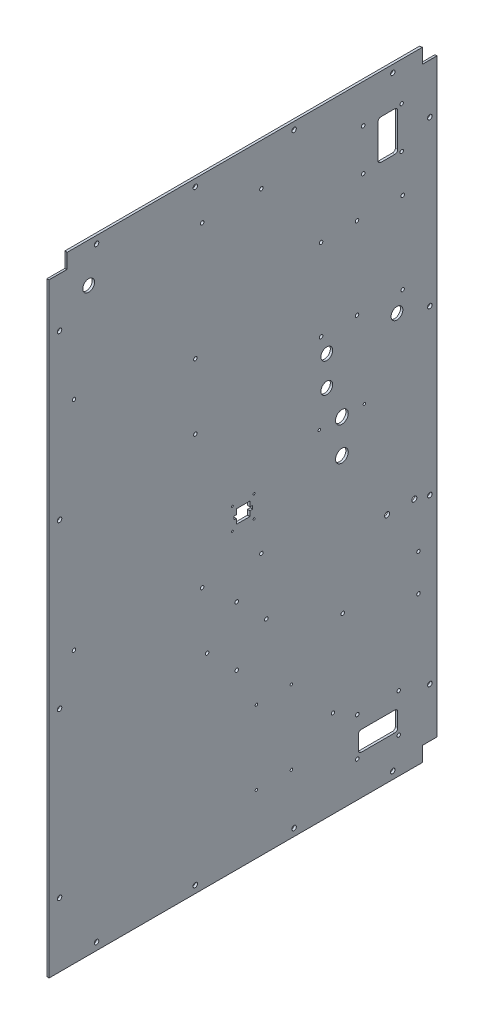
from build123d import *

# Parameters (mm, degrees)
SKETCH1_W                                   = 499.3132
SKETCH1_H                                   = 797.0266
SIDEPANEL_DEPTH                             = 3.0734
SKETCH2_R                                   = 2.8956
TOPBOTTOMHOLEMASTER_DEPTH                   = 4.0734
LPATTERN1_COUNT                             = 4
LPATTERN1_PITCH                             = 127.067733333
SKETCH3_R                                   = 2.8956
REARHOLESMASTER_DEPTH                       = 4.0734
LPATTERN2_COUNT                             = 4
LPATTERN2_PITCH                             = 210.574466667
SKETCH4_W                                   = 19.05
SKETCH4_H                                   = 19.05
SKETCH4_W_2                                 = 22.86
CORNERCUTS_DEPTH                            = 4.0734
F_8_CLEARANCE_HOLE4_BRAIN_MOUNT_D           = 4.4958
F_8_CLEARANCE_HOLE3_PUMP_MOUNTS_D           = 4.4958
SKETCH17_W                                  = 25.4
SKETCH17_H                                  = 50.8
SKETCH17_W_2                                = 50.8
SKETCH17_H_2                                = 25.4
CABLE_PASS_THROUGH_DEPTH                    = 4.0734
F_8_CLEARANCE_HOLE1_PASS_THROUGH_MOUNTING_D = 4.4958
CUT_EXTRUDE1_DEPTH                          = 2.54
F_8_CLEARANCE_HOLE_HX_MOUNT_D               = 4.4958
SKETCH42_R                                  = 7.578725
SKETCH42_R_2                                = 7.5819
COOLANT_HOSE_PASS_THROUGH_DEPTH             = 4.0734
SKETCH43_R                                  = 7.5819
AIR_FLUSH_IN_OUT_DEPTH                      = 4.0734
F_8_CLEARANCE_HOLE2_AIR_FLUSH_OUT_MOUNT_D   = 4.4958
F_8_CLEARANCE_HOLE4_PANEL_MOUNTS_D          = 4.4958
FILLET1_R                                   = 3.81
SKETCH50_OUTSIDE_W                          = 689.418
SKETCH50_OUTSIDE_H                          = 987.13
SKETCH50_OUTSIDE_R                          = 8.1915
SENSOR_MOUNTING_DEPTH                       = 4.0734
F_2_CLEARANCE_HOLE1_D                       = 2.4384
F_4_CLEARANCE_HOLE2_D                       = 3.2639
FILLET2_R                                   = 0.127
F_4_CLEARANCE_HOLE_COMPRESSOR_DRIVER_D      = 3.2639
F_1_4_CLEARANCE_HOLE_BALL_VALVE_U_BOLT_D    = 6.5278
AERATION_PUMP_8_CLEARANCE_HOLE1_D           = 4.3053


with BuildPart() as part:
    # Sketch1 → SidePanel (new body)
    with BuildSketch(Plane(origin=(0, 0, 0), x_dir=(0, 0, -1), z_dir=(1, 0, 0))):
        Rectangle(SKETCH1_W, SKETCH1_H)
    extrude(amount=SIDEPANEL_DEPTH)

    # Sketch2 → TopBottomHoleMaster (cut, through all)
    with BuildSketch(Plane(origin=(3.0734, 0, 0), x_dir=(0, 0, -1), z_dir=(1, 0, 0))):
        with Locations((192.5066, 388.9883)):
            Circle(SKETCH2_R)
        with Locations((192.5066, -388.9883)):
            Circle(SKETCH2_R)
    topbottomholemaster = extrude(amount=-TOPBOTTOMHOLEMASTER_DEPTH, mode=Mode.SUBTRACT)

    # LPattern1: TopBottomHoleMaster ×4
    with Locations(*[(0, 0, i * LPATTERN1_PITCH) for i in range(1, LPATTERN1_COUNT)]):
        add(topbottomholemaster, mode=Mode.SUBTRACT)

    # Sketch3 → RearHolesMaster (cut, through all)
    with BuildSketch(Plane(origin=(3.0734, 0, 0), x_dir=(0, 0, -1), z_dir=(1, 0, 0))):
        with Locations((-236.3216, 315.8617)):
            Circle(SKETCH3_R)
        with Locations((240.1316, 315.8617)):
            Circle(SKETCH3_R)
    rearholesmaster = extrude(amount=-REARHOLESMASTER_DEPTH, mode=Mode.SUBTRACT)

    # LPattern2: RearHolesMaster ×4
    with Locations(*[(0, -i * LPATTERN2_PITCH, 0) for i in range(1, LPATTERN2_COUNT)]):
        add(rearholesmaster, mode=Mode.SUBTRACT)

    # Sketch4 → CornerCuts (cut, through all)
    with BuildSketch(Plane.ZY):
        with Locations((-240.1316, 388.9883)):
            Rectangle(SKETCH4_W, SKETCH4_H)
        with Locations((238.2266, 388.9883)):
            Rectangle(SKETCH4_W_2, SKETCH4_H)
        with Locations((-240.1316, -388.9883)):
            Rectangle(SKETCH4_W, SKETCH4_H)
    extrude(amount=-CORNERCUTS_DEPTH, mode=Mode.SUBTRACT)

    # #8 Clearance Hole4 Brain Mount (through all)
    with Locations(Plane.ZY):
        with Locations((-23.3934, 344.4367), (52.8066, 344.4367), (52.8066, -61.9633), (-23.3934, -61.9633), (-146.4564, 141.8717), (-146.4564, 247.2817), (61.5696, 197.49262), (61.5696, 113.41862)):
            Hole(F_8_CLEARANCE_HOLE4_BRAIN_MOUNT_D / 2)

    # #8 Clearance Hole3 Pump Mounts (through all)
    with Locations(Plane.ZY):
        with Locations((46.4566, -138.1633), (8.3566, -100.0633), (8.3566, -176.2633), (-29.7434, -138.1633)):
            Hole(F_8_CLEARANCE_HOLE3_PUMP_MOUNTS_D / 2)

    # Sketch17 → Cable Pass Through (cut, through all)
    with BuildSketch(Plane.ZY):
        with Locations((-186.1566, 322.3133)):
            Rectangle(SKETCH17_W, SKETCH17_H)
        with Locations((-173.4566, -335.0133)):
            Rectangle(SKETCH17_W_2, SKETCH17_H_2)
    extrude(amount=-CABLE_PASS_THROUGH_DEPTH, mode=Mode.SUBTRACT)

    # #8 Clearance Hole1 Pass through Mounting holes (through all)
    with Locations(Plane(origin=(3.0734, 0, 0), x_dir=(0, 0, -1), z_dir=(1, 0, 0))):
        with Locations((146.7866, -352.7933), (200.1266, -352.7933), (200.1266, -303.2633), (146.7866, -303.2633), (154.4066, 348.9833), (203.9366, 348.9833), (203.9366, 295.6433), (154.4066, 295.6433)):
            Hole(F_8_CLEARANCE_HOLE1_PASS_THROUGH_MOUNTING_D / 2)

    # Sketch39 → Cut-Extrude1 (cut)
    with BuildSketch(Plane.ZY):
        Polygon((-230.2256, 398.5133), (-230.6066, 398.5133), (-230.6066, 379.4633), (-249.6566, 379.4633), (-249.6566, 379.0823), (-230.2256, 379.0823), align=None)
        Polygon((-249.6566, -379.0823), (-249.6566, -379.4633), (-230.6066, -379.4633), (-230.6066, -398.5133), (-230.2256, -398.5133), (-230.2256, -379.0823), align=None)
        Polygon((226.7966, 398.5133), (226.4156, 398.5133), (226.4156, 379.0823), (249.6566, 379.0823), (249.6566, 379.4633), (226.7966, 379.4633), align=None)
    extrude(amount=-CUT_EXTRUDE1_DEPTH, mode=Mode.SUBTRACT)

    # #8 Clearance Hole -hx mount (through all)
    with Locations(Plane(origin=(3.0734, 0, 0), x_dir=(0, 0, -1), z_dir=(1, 0, 0))):
        with Locations((205.2066, 246.1133), (205.2066, 141.1133), (100.2066, 141.1133), (100.2066, 246.1133)):
            Hole(F_8_CLEARANCE_HOLE_HX_MOUNT_D / 2)

    # Sketch42 → Coolant hose pass through (cut, through all)
    with BuildSketch(Plane(origin=(3.0734, 0, 0), x_dir=(0, 0, -1), z_dir=(1, 0, 0))):
        with Locations((197.8406, 118.5073)):
            Circle(SKETCH42_R)
        with Locations((107.5726, 118.5073)):
            Circle(SKETCH42_R_2)
    extrude(amount=-COOLANT_HOSE_PASS_THROUGH_DEPTH, mode=Mode.SUBTRACT)

    # Sketch43 → Air flush in/out (cut, through all)
    with BuildSketch(Plane(origin=(3.0734, 0, 0), x_dir=(0, 0, -1), z_dir=(1, 0, 0))):
        with Locations((-198.8566, 347.7133)):
            Circle(SKETCH43_R)
        with Locations((107.5726, 80.4073)):
            Circle(SKETCH43_R)
    extrude(amount=-AIR_FLUSH_IN_OUT_DEPTH, mode=Mode.SUBTRACT)

    # #8 Clearance Hole2 Air Flush Out mount (through all)
    with Locations(Plane(origin=(3.0734, 0, 0), x_dir=(0, 0, -1), z_dir=(1, 0, 0))):
        with Locations((225.5266, -160.7693), (225.5266, -208.0133), (128.067808498, -181.154848387)):
            Hole(F_8_CLEARANCE_HOLE2_AIR_FLUSH_OUT_MOUNT_D / 2)

    # #8 Clearance Hole4 Panel Mounts (through all)
    with Locations(Plane(origin=(3.0734, 0, 0), x_dir=(0, 0, -1), z_dir=(1, 0, 0))):
        with Locations((-217.7034, 230.1367), (-217.7034, -49.2633)):
            Hole(F_8_CLEARANCE_HOLE4_PANEL_MOUNTS_D / 2)

    # Fillet1
    fillet1_edges = [part.edges().sort_by_distance(p)[0] for p in [
        (1.5367, 296.9133, -198.8566),
        (1.5367, 347.7133, -198.8566),
        (1.5367, 347.7133, -173.4566),
        (1.5367, 296.9133, -173.4566),
        (1.5367, -347.7133, -198.8566),
        (1.5367, -322.3133, -198.8566),
        (1.5367, -322.3133, -148.0566),
        (1.5367, -347.7133, -148.0566),
    ]]
    fillet(fillet1_edges, radius=FILLET1_R)

    # Sketch50 outside → Sensor Mounting (cut, through all)
    with BuildSketch(Plane(origin=(3.0734, 0, 0), x_dir=(0, 0, -1), z_dir=(1, 0, 0))):
        Rectangle(SKETCH50_OUTSIDE_W, SKETCH50_OUTSIDE_H)
        Polygon((230.6066, -379.4633), (249.6566, -379.4633), (249.6566, 379.4633), (230.6066, 379.4633), (230.6066, 398.5133), (-226.7966, 398.5133), (-226.7966, 379.4633), (-249.6566, 379.4633), (-249.6566, -398.5133), (230.6066, -398.5133), align=None, mode=Mode.SUBTRACT)
        with Locations((127, -4.8133)):
            Circle(SKETCH50_OUTSIDE_R)
        with Locations((127, 38.3667)):
            Circle(SKETCH50_OUTSIDE_R)
        Polygon((-8.625, 3.8117), (8.625, 3.8117), (8.625, -2.6883), (12.125, -2.6883), (12.125, -6.9383), (8.625, -6.9383), (8.625, -13.4383), (-8.625, -13.4383), (-8.625, -6.9383), (-12.125, -6.9383), (-12.125, -2.6883), (-8.625, -2.6883), align=None)
    extrude(amount=-SENSOR_MOUNTING_DEPTH, mode=Mode.SUBTRACT)

    # #2 Clearance Hole1 (through all)
    with Locations(Plane(origin=(3.0734, 0, 0), x_dir=(0, 0, -1), z_dir=(1, 0, 0))):
        with Locations((-13.97, 9.1567), (13.97, 9.1567), (13.97, -18.7833), (-13.97, -18.7833)):
            Hole(F_2_CLEARANCE_HOLE1_D / 2)

    # #4 Clearance Hole2 (through all)
    with Locations(Plane(origin=(3.0734, 0, 0), x_dir=(0, 0, -1), z_dir=(1, 0, 0))):
        with Locations((98, 38.3667), (156, 38.3667)):
            Hole(F_4_CLEARANCE_HOLE2_D / 2)

    # Fillet2
    fillet2_edges = [part.edges().sort_by_distance(p)[0] for p in [
        (1.5367, -2.6883, 8.625),
        (1.5367, 3.8117, 8.625),
        (1.5367, 3.8117, -8.625),
        (1.5367, -2.6883, -8.625),
        (1.5367, -2.6883, -12.125),
        (1.5367, -6.9383, -12.125),
        (1.5367, -6.9383, -8.625),
        (1.5367, -13.4383, -8.625),
        (1.5367, -13.4383, 8.625),
        (1.5367, -6.9383, 8.625),
        (1.5367, -6.9383, 12.125),
        (1.5367, -2.6883, 12.125),
    ]]
    fillet(fillet2_edges, radius=FILLET2_R)

    # #4 Clearance Hole compressor driver (through all)
    with Locations(Plane.ZY):
        with Locations((-17.0434, -227.3133), (-62.0434, -227.3133), (-62.0434, -322.3133), (-17.0434, -322.3133)):
            Hole(F_4_CLEARANCE_HOLE_COMPRESSOR_DRIVER_D / 2)

    # 1/4 Clearance Hole ball valve u bolt (through all)
    with Locations(Plane(origin=(3.0734, 0, 0), x_dir=(0, 0, -1), z_dir=(1, 0, 0))):
        with Locations((220.1418, -99.7331), (185.2168, -99.7331)):
            Hole(F_1_4_CLEARANCE_HOLE_BALL_VALVE_U_BOLT_D / 2)

    # Aeration Pump #8 Clearance Hole1 (through all)
    with Locations(Plane(origin=(3.0734, 0, 0), x_dir=(0, 0, -1), z_dir=(1, 0, 0))):
        with Locations((115.51285, -285.8008)):
            Hole(AERATION_PUMP_8_CLEARANCE_HOLE1_D / 2)


solid = part.part
